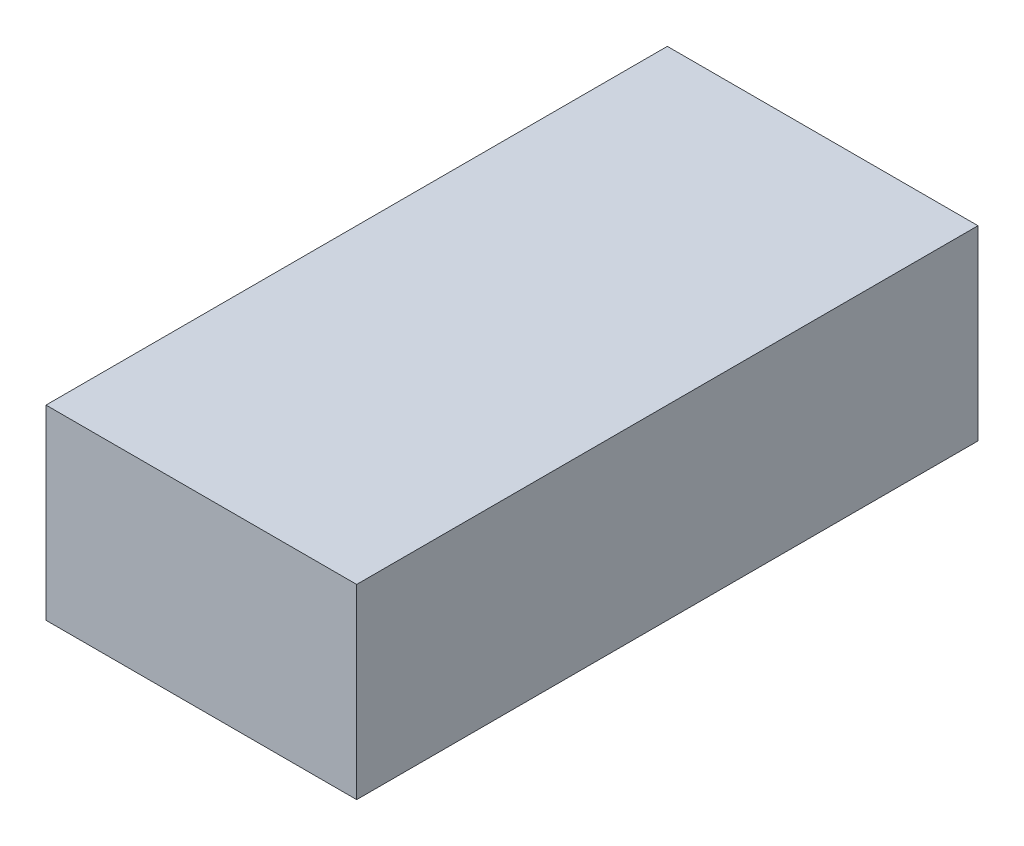
from build123d import *

# Parameters (mm, degrees)
BOSS_EXTRUDE1_DEPTH = 69
SKETCH4_W           = 15
SKETCH4_H           = 188.2
BOSS_EXTRUDE2_DEPTH = 61.9
BOSS_EXTRUDE3_DEPTH = 20.4
FILLET1_R           = 10
SKETCH6_W           = 10000
SKETCH6_H           = 3000
BOSS_EXTRUDE4_DEPTH = 2500
SKETCH7_W           = 952
SKETCH7_H           = 476
BOSS_EXTRUDE5_DEPTH = 238


with BuildPart() as part:
    # Sketch2 → Boss-Extrude1 (new body, symmetric)
    with BuildSketch(Plane(origin=(0, 0, 0), x_dir=(0, 0, -1), z_dir=(1, 0, 0))):
        with BuildLine():
            Line((-262.793626597, 0), (0, 0))
            Line((0, 0), (203.2, 0))
            Line((203.2, 0), (203.2, 81.9))
            Line((203.2, 81.9), (188.2, 81.9))
            Line((188.2, 81.9), (188.2, 20))
            Line((188.2, 20), (0, 20))
            Line((0, 20), (0, 133.7))
            Line((0, 133.7), (-115, 133.7))
            Line((-115, 133.7), (-171.193830238, 94.352656466))
            Line((-171.193830238, 94.352656466), (-262.793626597, 81.479144628))
            Line((-262.793626597, 81.479144628), (-262.793626597, 31.479144628))
            ThreePointArc((-262.793626597, 31.479144628), (-272.644060375, 15.739572314), (-262.793626597, 0))
        make_face()
    extrude(amount=BOSS_EXTRUDE1_DEPTH, both=True)

    # Sketch4 → Boss-Extrude2 (add)
    with BuildSketch(Plane(origin=(0, 20, 0), x_dir=(1, 0, 0), z_dir=(0, 1, 0))):
        with Locations((61.5, 94.1)):
            Rectangle(SKETCH4_W, SKETCH4_H)
    boss_extrude2 = extrude(amount=BOSS_EXTRUDE2_DEPTH)

    # Mirror1: Boss-Extrude2 across plane
    add(boss_extrude2.mirror(Plane(origin=(0, 0, 0), x_dir=(0, 0, 1), z_dir=(1, 0, 0))))

    # Sketch5 → Boss-Extrude3 (add)
    with BuildSketch(Plane(origin=(69, 0, 0), x_dir=(0, 0, -1), z_dir=(1, 0, 0))):
        with BuildLine():
            Line((-224.944060375, 0), (-160.344060375, 0))
            ThreePointArc((-160.344060375, 0), (-192.644060375, -32.3), (-224.944060375, 0))
        make_face()
        with BuildLine():
            Line((28.055939625, 0), (92.655939625, 0))
            ThreePointArc((92.655939625, 0), (60.355939625, -32.3), (28.055939625, 0))
        make_face()
    boss_extrude3 = extrude(amount=-BOSS_EXTRUDE3_DEPTH)

    # Mirror2: Boss-Extrude3 across plane
    add(boss_extrude3.mirror(Plane(origin=(0, 0, 0), x_dir=(0, 0, 1), z_dir=(1, 0, 0))))

    # Fillet1
    fillet1_edges = [part.edges().sort_by_distance(p)[0] for p in [
        (0, 31.479144628, 262.793626597),
        (0, 81.479144628, 262.793626597),
        (0, 94.352656466, 171.193830238),
        (0, 133.7, 115),
        (0, 133.7, 0),
    ]]
    fillet(fillet1_edges, radius=FILLET1_R)


with BuildPart() as body_2:
    # Sketch6 → Boss-Extrude4 (new body, symmetric)
    with BuildSketch(Plane(origin=(0, 0, 0), x_dir=(0, 0, -1), z_dir=(1, 0, 0))):
        with Locations((2727.48649749, 1467.7)):
            Rectangle(SKETCH6_W, SKETCH6_H)
    extrude(amount=BOSS_EXTRUDE4_DEPTH, both=True)


with BuildPart() as body_3:
    # Sketch7 → Boss-Extrude5 (new body, symmetric)
    with BuildSketch(Plane(origin=(0, 0, 0), x_dir=(0, 0, -1), z_dir=(1, 0, 0))):
        with Locations((45.355939625, 205.7)):
            Rectangle(SKETCH7_W, SKETCH7_H)
    extrude(amount=BOSS_EXTRUDE5_DEPTH, both=True)


solid = Compound([part.part, body_2.part, body_3.part])
